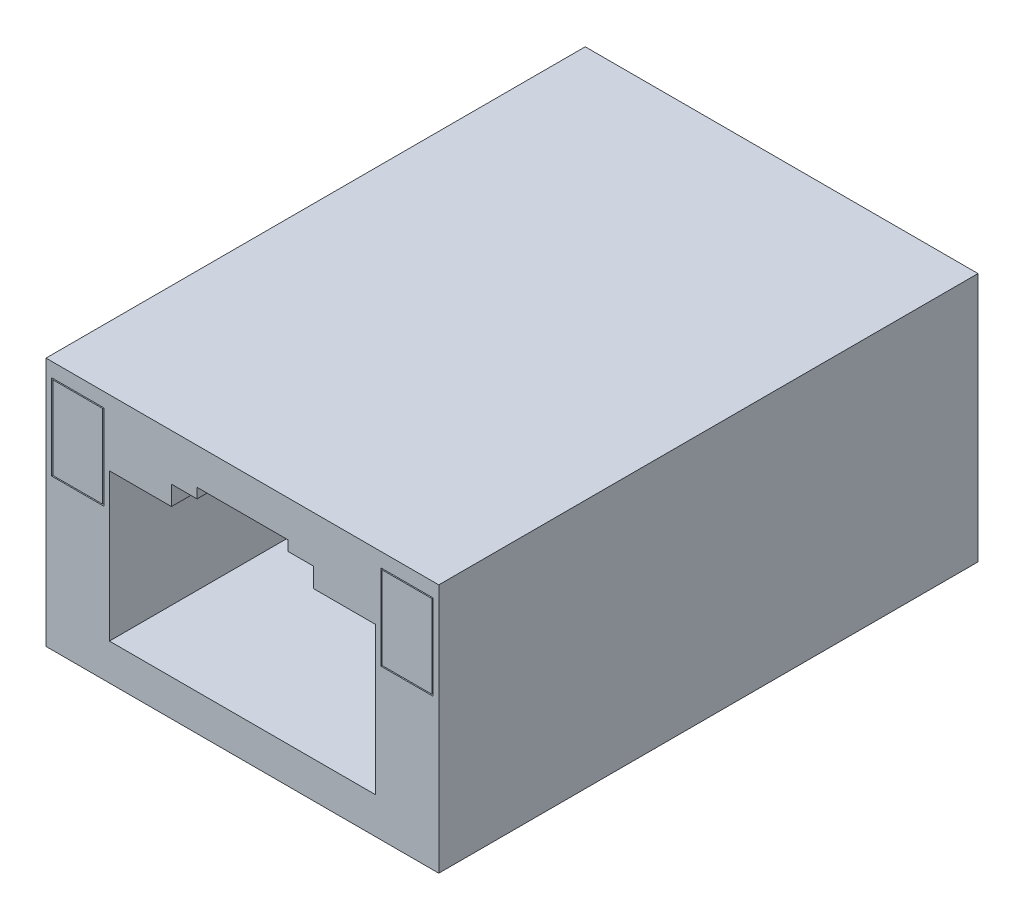
from build123d import *

# Parameters (mm, degrees)
SKETCH1_W           = 17.5768
SKETCH1_H           = 11.176
BOSS_EXTRUDE1_DEPTH = 24.13
CUT_EXTRUDE1_DEPTH  = 22.55
SKETCH3_W           = 2.3304
SKETCH3_H           = 3.81
SKETCH3_W_2         = 2.2288
SKETCH3_H_2         = 3.7084
CUT_EXTRUDE2_DEPTH  = 0.254


with BuildPart() as part:
    # Sketch1 → Boss-Extrude1 (new body)
    with BuildSketch(Plane.XY):
        with Locations((8.7884, 5.588)):
            Rectangle(SKETCH1_W, SKETCH1_H)
    extrude(amount=-BOSS_EXTRUDE1_DEPTH)

    # Sketch2 → Cut-Extrude1 (cut)
    with BuildSketch(Plane.XY):
        Polygon((2.8384, 1.628), (14.7384, 1.628), (14.7384, 8.228), (11.9634, 8.228), (11.9634, 9.098), (10.8184, 9.098), (10.8184, 9.548), (6.7584, 9.548), (6.7584, 9.098), (5.6134, 9.098), (5.6134, 8.228), (2.8384, 8.228), align=None)
    extrude(amount=-CUT_EXTRUDE1_DEPTH, mode=Mode.SUBTRACT)

    # Sketch3 → Cut-Extrude2 (cut)
    with BuildSketch(Plane.XY):
        with Locations((1.4192, 8.636)):
            Rectangle(SKETCH3_W, SKETCH3_H)
        with Locations((1.4192, 8.636)):
            Rectangle(SKETCH3_W_2, SKETCH3_H_2, mode=Mode.SUBTRACT)
        with Locations((16.1576, 8.636)):
            Rectangle(SKETCH3_W, SKETCH3_H)
        with Locations((16.1576, 8.636)):
            Rectangle(SKETCH3_W_2, SKETCH3_H_2, mode=Mode.SUBTRACT)
    extrude(amount=-CUT_EXTRUDE2_DEPTH, mode=Mode.SUBTRACT)


solid = part.part
